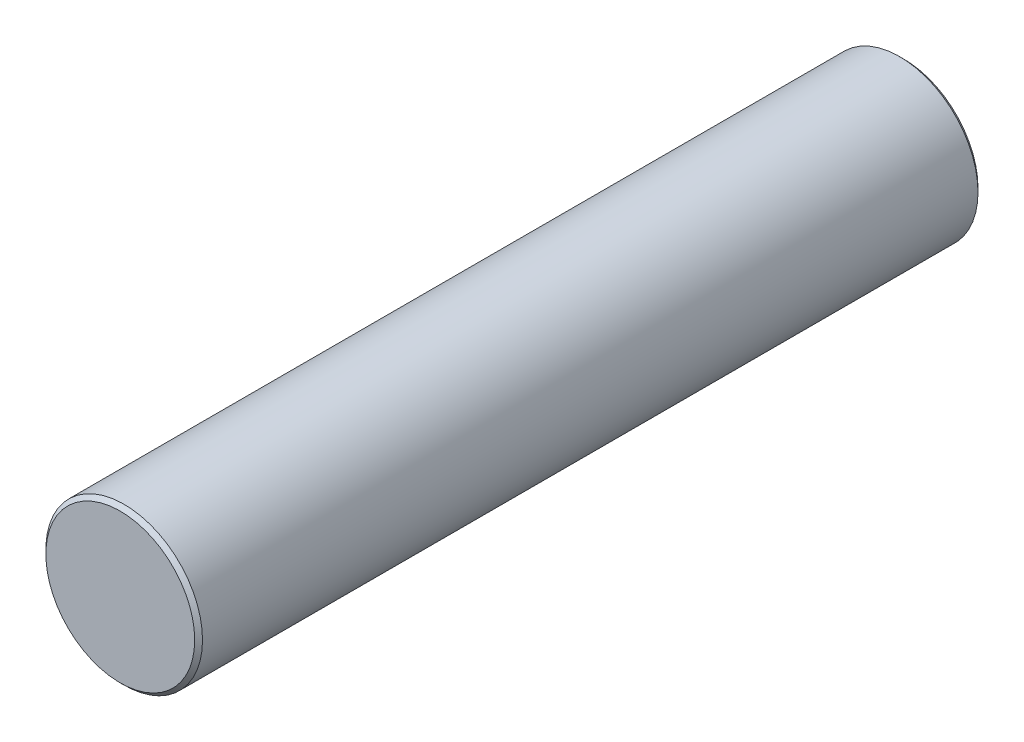
from build123d import *

# Parameters (mm, degrees)
SKETCH1_R           = 20
BOSS_EXTRUDE1_DEPTH = 200
CHAMFER1_SIZE       = 1


with BuildPart() as part:
    # Sketch1 → Boss-Extrude1 (new body)
    with BuildSketch(Plane.XY):
        Circle(SKETCH1_R)
    extrude(amount=BOSS_EXTRUDE1_DEPTH)

    # Chamfer1
    chamfer1_edges = [part.edges().sort_by_distance(p)[0] for p in [
        (-20, 0, 0),
        (-20, 0, 200),
    ]]
    chamfer(chamfer1_edges, length=CHAMFER1_SIZE)


solid = part.part
